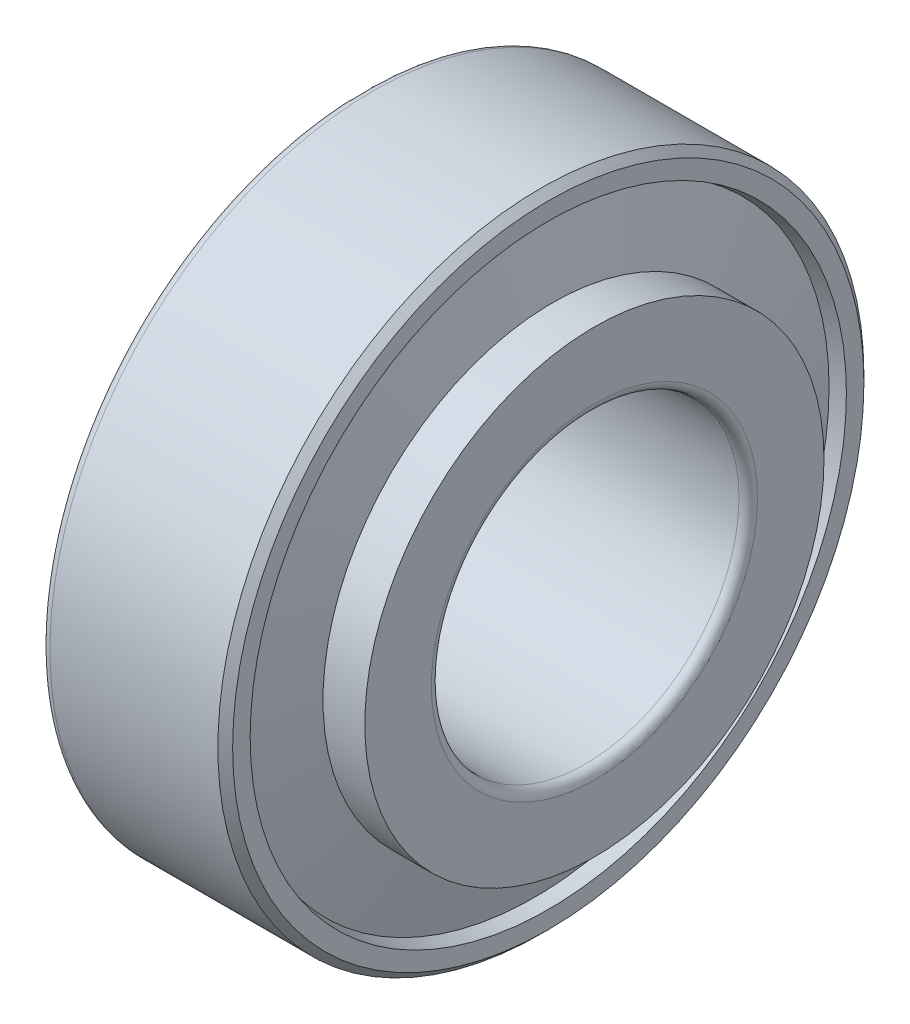
from build123d import *


with BuildPart() as part:
    # OutRacSke → OuterRace (revolve)
    with BuildSketch(Plane.XY):
        with BuildLine():
            Line((-3, 19.382436034), (-15, 16.3905))
            Line((-15, 16.3905), (-15, 20.4))
            ThreePointArc((-15, 20.4), (-14.824264069, 20.824264069), (-14.4, 21))
            Line((-14.4, 21), (-3.48, 21))
            Line((-3.48, 21), (-3, 20.52))
            Line((-3, 20.52), (-3, 19.382436034))
        make_face()
    revolve(axis=Axis((-42.5, 0, 0), (1, 0, 0)))

    # RolSimSke → RollersSimplified (revolve)
    with BuildSketch(Plane.XY):
        Polygon((-14.4, 16.622797286), (-3.920806156, 19.235553758), (-2.723292773, 14.432589913), (-13.202486617, 11.81983344), align=None)
    revolve(axis=Axis((0, 0, 0), (-1, 0, 0)))

    # InsRacSke → InnerRace (revolve)
    with BuildSketch(Plane.XY):
        with BuildLine():
            Line((-13.258207732, 12.06733344), (-15, 12.06733344))
            Line((-15, 12.06733344), (-15, 10.48))
            Line((-15, 10.48), (-14.52, 10))
            Line((-14.52, 10), (-0.6, 10))
            ThreePointArc((-0.6, 10), (-0.175735931, 10.175735931), (0, 10.6))
            Line((0, 10.6), (0, 14.927589913))
            Line((0, 14.927589913), (-2.717305207, 14.927589913))
            Line((-2.717305207, 14.927589913), (-2.717305207, 14.432589913))
            Line((-2.717305207, 14.432589913), (-13.196499051, 11.81983344))
            Line((-13.196499051, 11.81983344), (-13.258207732, 12.06733344))
        make_face()
    revolve(axis=Axis((-42.5, 0, 0), (1, 0, 0)))


solid = part.part
